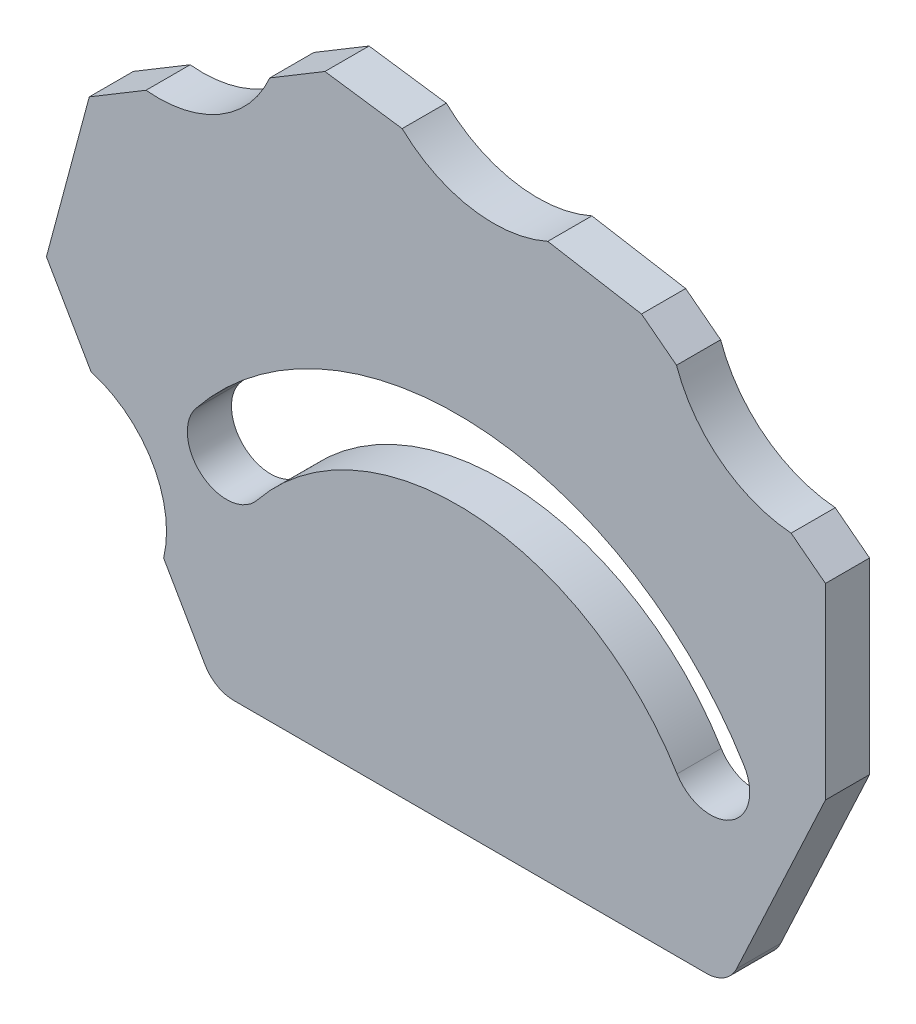
from build123d import *

# Parameters (mm, degrees)
BOSS_EXTRUDE1_DEPTH = 4
FILLET1_R           = 3


with BuildPart() as part:
    # Sketch1 → Boss-Extrude1 (new body)
    with BuildSketch(Plane.XY):
        with BuildLine():
            Line((-146.758239428, -31.610515221), (-100.258239428, -31.610515221))
            Line((-100.258239428, -31.610515221), (-91.398393923, -12.610515221))
            Line((-91.398393923, -12.610515221), (-91.398393923, 4.389484779))
            Line((-91.398393923, 4.389484779), (-94.509492228, 6.780828765))
            ThreePointArc((-94.509492228, 6.780828765), (-100.889202751, 9.230316509), (-104.897213893, 14.765345257))
            Line((-104.897213893, 14.765345257), (-108.065854757, 17.200919299))
            Line((-108.065854757, 17.200919299), (-116.565854757, 18.652315204))
            ThreePointArc((-116.565854757, 18.652315204), (-123.504827753, 17.774994873), (-129.759511963, 20.90516462))
            Line((-129.759511963, 20.90516462), (-136.759511963, 21.888950463))
            Line((-136.759511963, 21.888950463), (-141.759511963, 18.884647367))
            ThreePointArc((-141.759511963, 18.884647367), (-146.29133737, 13.762936165), (-152.973799535, 12.308953164))
            Line((-152.973799535, 12.308953164), (-158.116803339, 9.218724715))
            Line((-158.116803339, 9.218724715), (-161.999089016, -5.27016268))
            Line((-161.999089016, -5.27016268), (-157.957637132, -12.27016268))
            ThreePointArc((-157.957637132, -12.27016268), (-152.397461521, -16.623171082), (-151.377041582, -23.610515221))
            Line((-151.377041582, -23.610515221), (-146.758239428, -31.610515221))
        make_face()
        with BuildLine():
            ThreePointArc((-98.776012151, -13.587867208), (-122.779946794, 0.93416519), (-148.448407118, -10.388751744))
            ThreePointArc((-148.448407118, -10.388751744), (-147.89790448, -15.381816967), (-142.904839257, -14.83131433))
            ThreePointArc((-142.904839257, -14.83131433), (-123.236532063, -6.155195631), (-104.843657911, -17.282617793))
            ThreePointArc((-104.843657911, -17.282617793), (-99.962459738, -18.46906538), (-98.776012151, -13.587867208))
        make_face(mode=Mode.SUBTRACT)
    extrude(amount=BOSS_EXTRUDE1_DEPTH)

    # Fillet1
    fillet1_edges = [part.edges().sort_by_distance(p)[0] for p in [
        (-146.758239428, -31.610515221, 2),
        (-100.258239428, -31.610515221, 2),
    ]]
    fillet(fillet1_edges, radius=FILLET1_R)


solid = part.part
